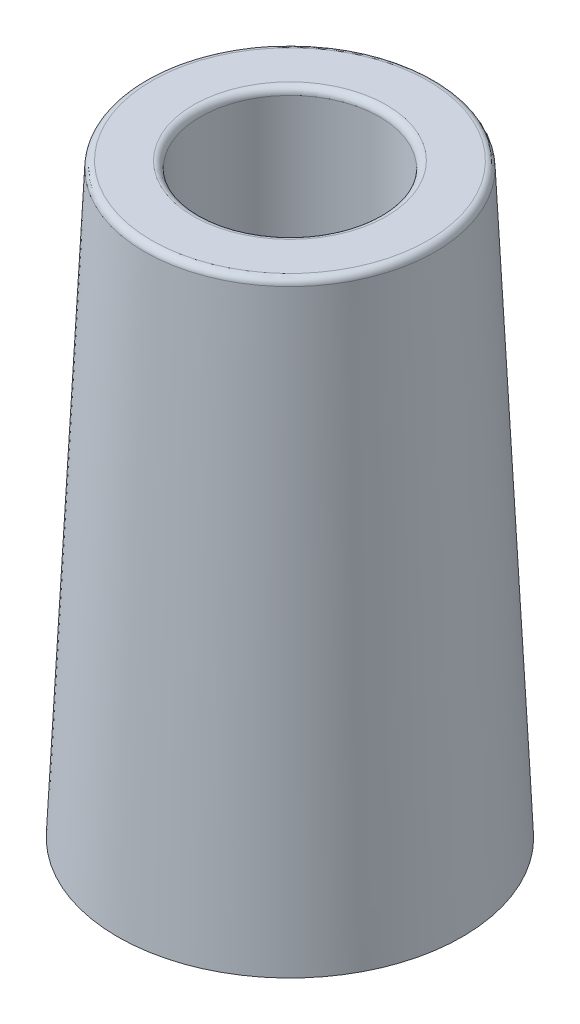
from build123d import *

# Parameters (mm, degrees)
SKETCH3_R          = 21
SKETCH1_3_R        = 25
SKETCH4_R          = 13
CUT_EXTRUDE2_DEPTH = 81
FILLET2_R          = 1


with BuildPart() as part:
    # Sketch3 → Loft1 section 0
    with BuildSketch(Plane(origin=(0, 85, 0), x_dir=(1, 0, 0), z_dir=(0, 1, 0))):
        Circle(SKETCH3_R)
    # Sketch1_3 → Loft1 section 1
    with BuildSketch(Plane(origin=(0, 0, 0), x_dir=(1, 0, 0), z_dir=(0, 1, 0))):
        Circle(SKETCH1_3_R)
    loft()

    # Sketch4 → Cut-Extrude2 (cut)
    with BuildSketch(Plane(origin=(0, 85, 0), x_dir=(1, 0, 0), z_dir=(0, 1, 0))):
        Circle(SKETCH4_R)
    extrude(amount=-CUT_EXTRUDE2_DEPTH, mode=Mode.SUBTRACT)

    # Fillet2
    fillet2_edges = [part.edges().sort_by_distance(p)[0] for p in [
        (-21, 85, 0),
        (-13, 85, 0),
    ]]
    fillet(fillet2_edges, radius=FILLET2_R)


solid = part.part
